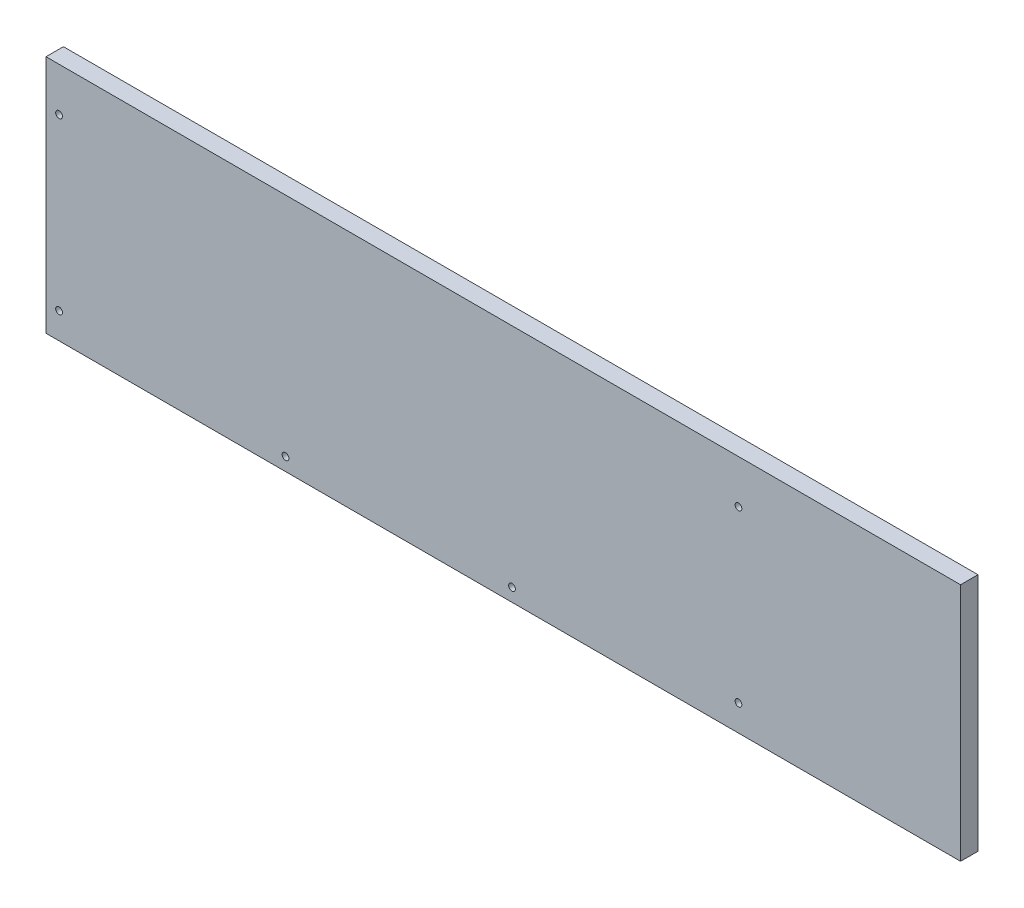
from build123d import *

# Parameters (mm, degrees)
SKETCH1_W           = 420
SKETCH1_H           = 110
BOSS_EXTRUDE1_DEPTH = 8
SKETCH2_R           = 1.55
CUT_EXTRUDE4_DEPTH  = 9


with BuildPart() as part:
    # Sketch1 → Boss-Extrude1 (new body)
    with BuildSketch(Plane.XY):
        Rectangle(SKETCH1_W, SKETCH1_H)
    extrude(amount=BOSS_EXTRUDE1_DEPTH)

    # Sketch2 → Cut-Extrude4 (cut, through all)
    with BuildSketch(Plane.XY):
        with Locations((-204, 35)):
            Circle(SKETCH2_R)
        with Locations((-204, -43)):
            Circle(SKETCH2_R)
        with Locations((-100, -49)):
            Circle(SKETCH2_R)
        with Locations((4, -49)):
            Circle(SKETCH2_R)
        with Locations((108, -43)):
            Circle(SKETCH2_R)
        with Locations((108, 35)):
            Circle(SKETCH2_R)
    extrude(amount=CUT_EXTRUDE4_DEPTH, mode=Mode.SUBTRACT)


solid = part.part
